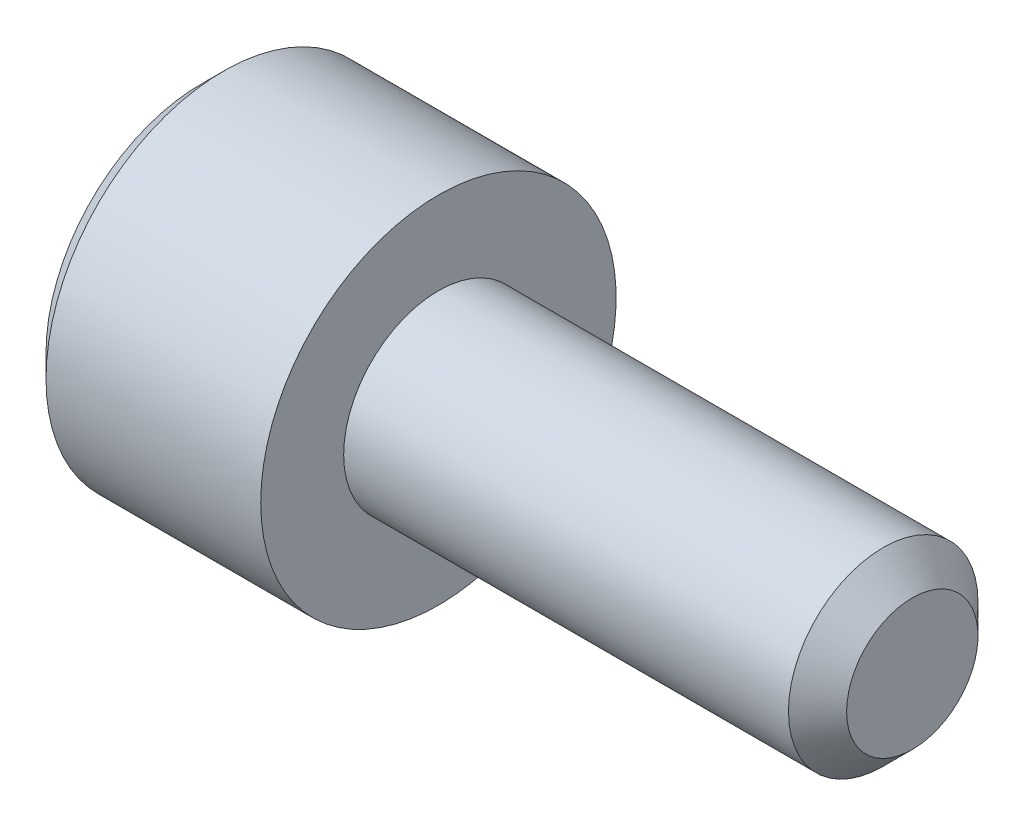
from build123d import *

# Parameters (mm, degrees)
CUT_EXTRUDE1_DEPTH = 1


with BuildPart() as part:
    # Sketch1 → Revolve1 (revolve)
    with BuildSketch(Plane.XY):
        Polygon((-2, 0), (-2, 1.3125), (-1.8125, 1.5), (0, 1.5), (0, 0.8), (3.7545, 0.8), (4, 0.5545), (4, 0), align=None)
    revolve(axis=Axis((4, 0, 0), (-1, 0, 0)))

    # Sketch2 → Cut-Revolve1 (revolve, cut)
    with BuildSketch(Plane.XY):
        Polygon((-2, 0), (-2, 0.9), (-1.85, 0.75), (-1, 0.75), (-0.6, 0), align=None)
    revolve(axis=Axis((-0.6, 0, 0), (-1, 0, 0)), mode=Mode.SUBTRACT)

    # Sketch3 → Cut-Extrude1 (cut)
    with BuildSketch(Plane(origin=(-2, 0, 0), x_dir=(0, 0, -1), z_dir=(1, 0, 0))):
        Polygon((-0.75, -0.433012702), (0, -0.866025404), (0.75, -0.433012702), (0.75, 0.433012702), (0, 0.866025404), (-0.75, 0.433012702), align=None)
    extrude(amount=CUT_EXTRUDE1_DEPTH, mode=Mode.SUBTRACT)


solid = part.part
